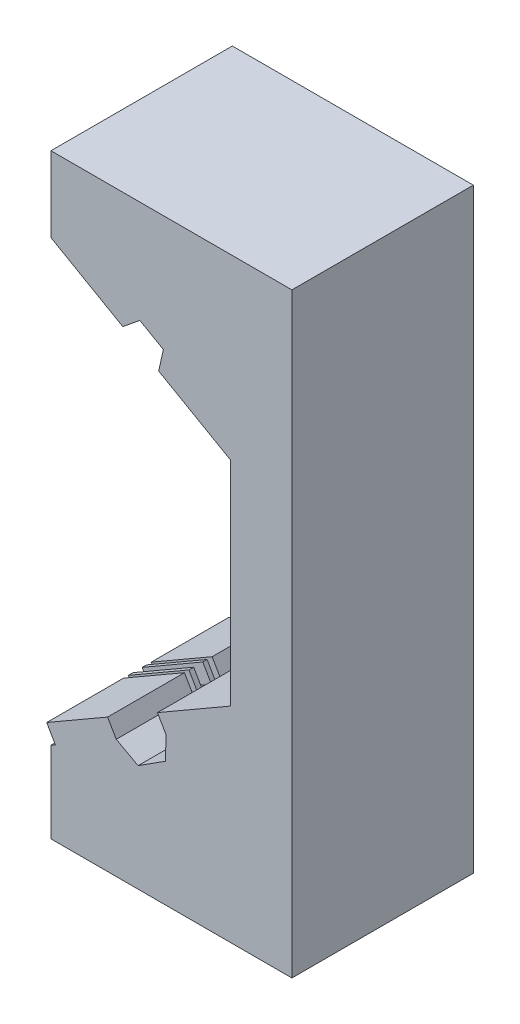
from build123d import *

# Parameters (mm, degrees)
BOSS_EXTRUDE1_DEPTH      = 10
BOSS_EXTRUDE1_DEPTH_BACK = 11
SKETCH2_W                = 0.5
SKETCH2_H                = 33.789751219
SKETCH2_W_2              = 8.9
SKETCH2_H_2              = 33.710181146
BOSS_EXTRUDE2_DEPTH      = 0.9
SKETCH4_W                = 3.2
SKETCH4_H                = 3.035313039
CUT_EXTRUDE1_DEPTH       = 0.9
SKETCH5_W                = 8.9
SKETCH5_H                = 5.924846374
SKETCH5_H_2              = 8.259633143
BOSS_EXTRUDE3_DEPTH      = 3.9
SKETCH6_W                = 10.051459914
SKETCH6_H                = 8.9
SKETCH6_W_2              = 8.141320355
SKETCH6_W_3              = 10.023699464
SKETCH6_H_2              = 0.55
SKETCH6_H_3              = 0.5
SKETCH6_W_4              = 8.105756988
BOSS_EXTRUDE4_DEPTH      = 2


with BuildPart() as part:
    # Sketch1 → Boss-Extrude1 (new body, two sides)
    with BuildSketch(Plane.XY) as boss_extrude1_sk:
        Polygon((0.795322437, -25.455965093), (8.355079741, -21.091337178), (10.890469069, -22.462482859), (14.044123283, -20.446434454), (14.129516604, -17.757464501), (22.479597834, -12.936542855), (22.479597834, -1.543644942), (23.016460709, -1.543644942), (23.016460709, -1.327475501), (23.549450475, -1.327475501), (24.148188576, -0.947681864), (24.148188576, 0.979689608), (23.549450475, 1.278840764), (23.016460709, 1.278840764), (23.016460709, 1.491668097), (22.479597834, 1.491668097), (22.479597834, 13.01230949), (13.267337289, 18.286375916), (13.8113599, 20.713241045), (11.090051556, 22.271204034), (9.1144107, 20.663947694), (0.795322437, 25.426668406), (0.795322437, 34.137830746), (28.694115234, 34.137830746), (28.694115234, -34.851518664), (0.795322437, -34.851518664), align=None)
    extrude(amount=BOSS_EXTRUDE1_DEPTH)
    extrude(boss_extrude1_sk.sketch, amount=-BOSS_EXTRUDE1_DEPTH_BACK)

    # Sketch2 → Boss-Extrude2 (add)
    with BuildSketch(Plane.ZY.offset(-22.479597834)):
        with Locations((-1.3, 1.391500307)):
            Rectangle(SKETCH2_W, SKETCH2_H)
        with Locations((-6.55, 1.391500307)):
            Rectangle(SKETCH2_W_2, SKETCH2_H)
        with Locations((5.55, 1.431285343)):
            Rectangle(SKETCH2_W_2, SKETCH2_H_2)
        with Locations((0.3, 1.431285343)):
            Rectangle(SKETCH2_W, SKETCH2_H_2)
    extrude(amount=BOSS_EXTRUDE2_DEPTH)

    # Sketch4 → Cut-Extrude1 (cut)
    with BuildSketch(Plane.ZY.offset(-21.579597834)):
        with Locations((-0.5, -0.025988422)):
            Rectangle(SKETCH4_W, SKETCH4_H)
    extrude(amount=-CUT_EXTRUDE1_DEPTH, mode=Mode.SUBTRACT)

    # Sketch5 → Boss-Extrude3 (add)
    with BuildSketch(Plane.ZY.offset(-21.579597834)):
        with Locations((5.55, -0.357470261)):
            Rectangle(SKETCH5_W, SKETCH5_H)
        with Locations((-6.55, -0.62015136)):
            Rectangle(SKETCH5_W, SKETCH5_H_2)
    extrude(amount=-BOSS_EXTRUDE3_DEPTH)

    # Sketch6 → Boss-Extrude4 (add)
    with BuildSketch(Plane(origin=(11.221586833, -19.436358537, 0), x_dir=(0.866025404, 0.5, 0), z_dir=(-0.5, 0.866025404, 0))):
        with Locations((8.383518028, -5.55)):
            Rectangle(SKETCH6_W, SKETCH6_H)
        with Locations((8.383518028, 6.55)):
            Rectangle(SKETCH6_W, SKETCH6_H)
        with Locations((-7.38061746, -5.55)):
            Rectangle(SKETCH6_W_2, SKETCH6_H)
        with Locations((8.397398253, -0.275)):
            Rectangle(SKETCH6_W_3, SKETCH6_H_2)
        with Locations((8.397398253, 1.3)):
            Rectangle(SKETCH6_W_3, SKETCH6_H_3)
        with Locations((-7.398399144, -0.275)):
            Rectangle(SKETCH6_W_4, SKETCH6_H_2)
        with Locations((-7.398399144, 1.3)):
            Rectangle(SKETCH6_W_4, SKETCH6_H_3)
        with Locations((-7.38061746, 6.55)):
            Rectangle(SKETCH6_W_2, SKETCH6_H)
    extrude(amount=BOSS_EXTRUDE4_DEPTH)


solid = part.part
